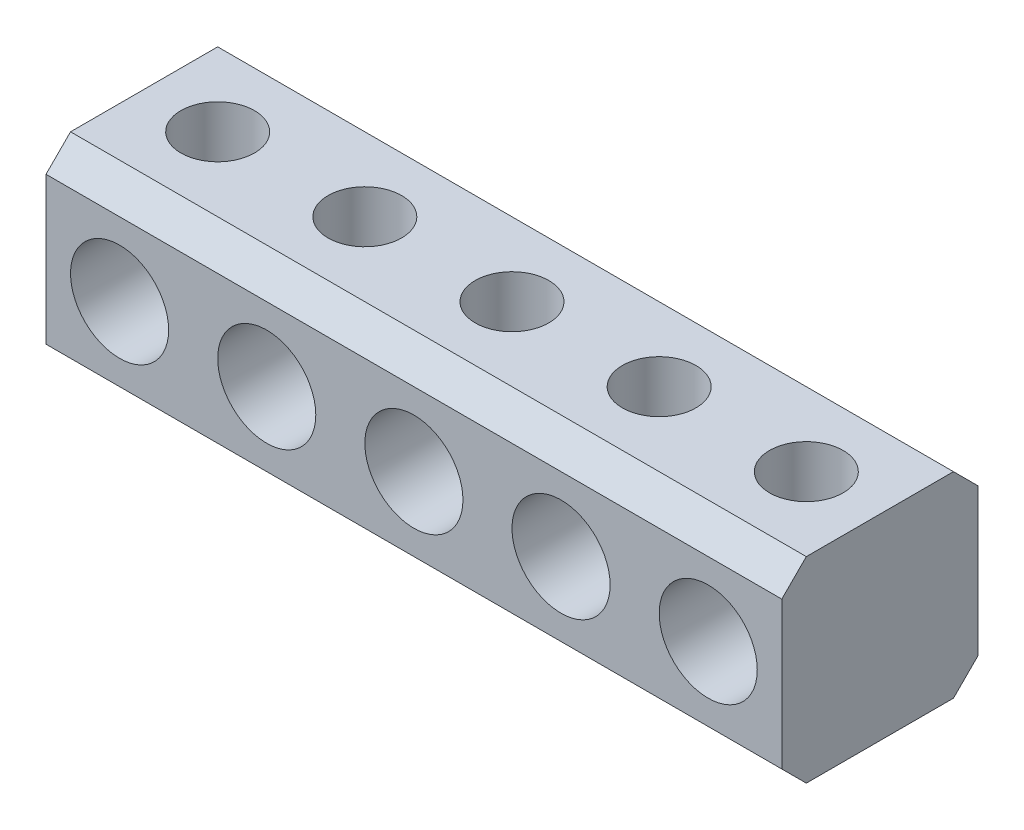
from build123d import *

# Parameters (mm, degrees)
CROQUIS1_W              = 300
CROQUIS1_H              = 80
SALIENTE_EXTRUIR1_DEPTH = 80
CHAFL_N1_SIZE           = 10
CROQUIS2_R              = 20
CORTAR_EXTRUIR1_DEPTH   = 40
CROQUIS3_R              = 15
CORTAR_EXTRUIR2_DEPTH   = 100


with BuildPart() as part:
    # Croquis1 → Saliente-Extruir1 (new body)
    with BuildSketch(Plane(origin=(0, 0, 0), x_dir=(1, 0, 0), z_dir=(0, 1, 0))):
        with Locations((-82.708690096, 15.857316294)):
            Rectangle(CROQUIS1_W, CROQUIS1_H)
    extrude(amount=SALIENTE_EXTRUIR1_DEPTH)

    # Chaflán1
    chafl_n1_edges = [part.edges().sort_by_distance(p)[0] for p in [
        (-82.708690096, 80, 24.142683706),
        (-82.708690096, 0, 24.142683706),
        (-82.708690096, 0, -55.857316294),
        (-82.708690096, 80, -55.857316294),
    ]]
    chamfer(chafl_n1_edges, length=CHAFL_N1_SIZE)

    # Croquis2 → Cortar-Extruir1 (cut)
    with BuildSketch(Plane.XY.offset(24.142683706)):
        with Locations((-82.708690096, 40)):
            Circle(CROQUIS2_R)
        with Locations((-142.708690096, 40)):
            Circle(CROQUIS2_R)
        with Locations((-202.708690096, 40)):
            Circle(CROQUIS2_R)
        with Locations((-22.708690096, 40)):
            Circle(CROQUIS2_R)
        with Locations((37.291309904, 40)):
            Circle(CROQUIS2_R)
    extrude(amount=-CORTAR_EXTRUIR1_DEPTH, mode=Mode.SUBTRACT)

    # Croquis3 → Cortar-Extruir2 (cut, symmetric)
    with BuildSketch(Plane(origin=(0, 80, 0), x_dir=(1, 0, 0), z_dir=(0, 1, 0))):
        with Locations((-82.708690096, 15.857316294)):
            Circle(CROQUIS3_R)
        with Locations((-22.708690096, 15.857316294)):
            Circle(CROQUIS3_R)
        with Locations((37.291309904, 15.857316294)):
            Circle(CROQUIS3_R)
        with Locations((-142.708690096, 15.857316294)):
            Circle(CROQUIS3_R)
        with Locations((-202.708690096, 15.857316294)):
            Circle(CROQUIS3_R)
    extrude(amount=CORTAR_EXTRUIR2_DEPTH, both=True, mode=Mode.SUBTRACT)


solid = part.part
